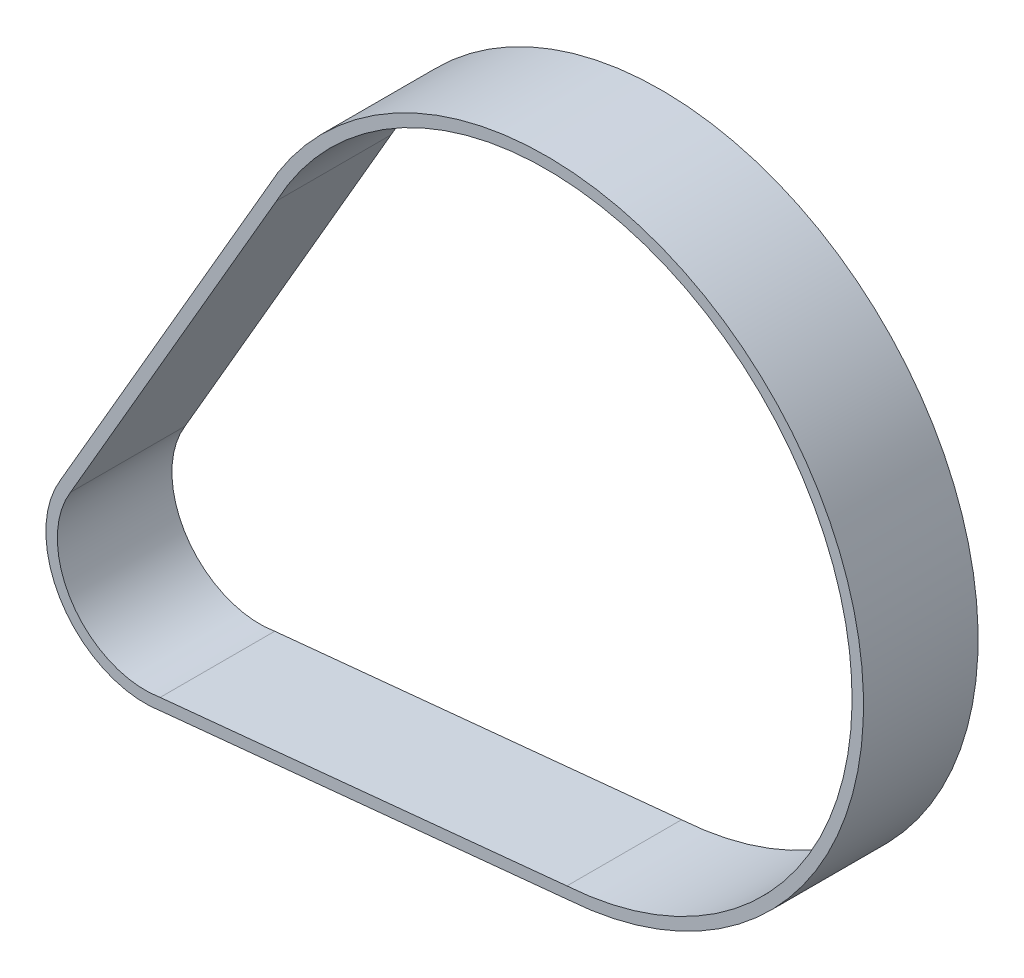
from build123d import *

# Parameters (mm, degrees)
BOSS_EXTRUDE1_DEPTH = 15


with BuildPart() as part:
    # Sketch1 → Boss-Extrude1 (new body)
    with BuildSketch(Plane.XY):
        with BuildLine():
            Line((-11.075505528, 6.806847824), (15.86921707, 53.277945579))
            ThreePointArc((15.86921707, 53.277945579), (87.350520076, 56.412264504), (55.331300302, -7.573438583))
            Line((55.331300302, -7.573438583), (2.161009026, -12.819127895))
            ThreePointArc((2.161009026, -12.819127895), (-10.777838035, -7.268989427), (-11.075505528, 6.806847824))
        make_face()
        with BuildLine():
            Line((-9.787793082, 6.037309548), (17.181207534, 52.550279181))
            ThreePointArc((17.181207534, 52.550279181), (86.090586967, 55.598277106), (55.207243092, -6.07839544))
            Line((55.207243092, -6.07839544), (1.960892298, -11.331588653))
            ThreePointArc((1.960892298, -11.331588653), (-9.525478998, -6.443232873), (-9.787793082, 6.037309548))
        make_face(mode=Mode.SUBTRACT)
    extrude(amount=BOSS_EXTRUDE1_DEPTH)


solid = part.part
